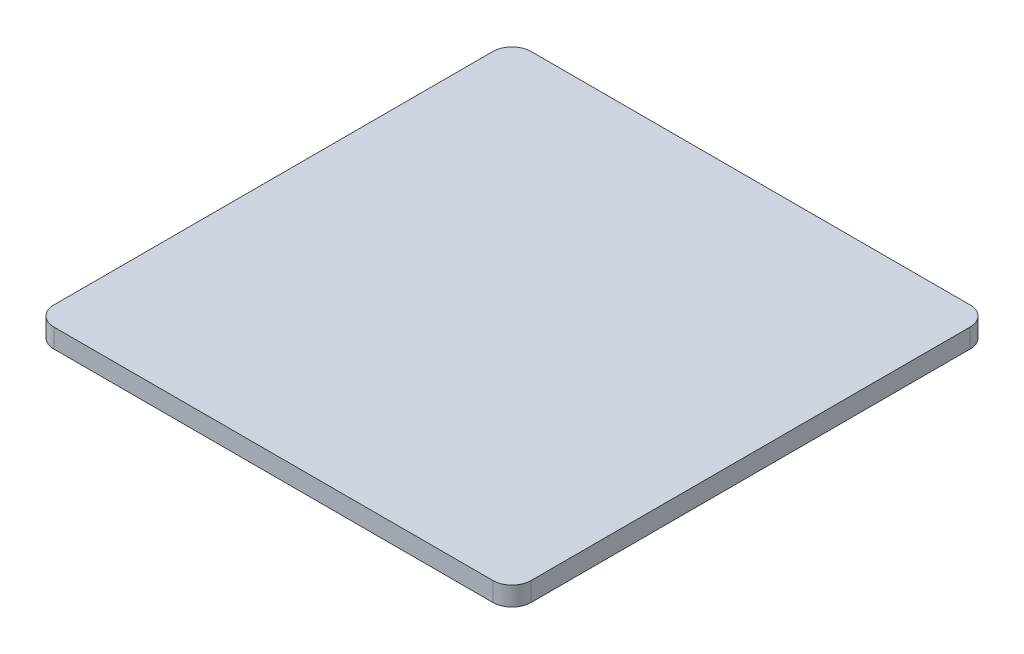
from build123d import *

# Parameters (mm, degrees)
SKETCH1_W           = 127
SKETCH1_H           = 127
BOSS_EXTRUDE1_DEPTH = 5.08
FILLET1_R           = 5.08


with BuildPart() as part:
    # Sketch1 → Boss-Extrude1 (new body)
    with BuildSketch(Plane(origin=(0, 0, 0), x_dir=(1, 0, 0), z_dir=(0, 1, 0))):
        Rectangle(SKETCH1_W, SKETCH1_H)
    extrude(amount=BOSS_EXTRUDE1_DEPTH)

    # Fillet1
    fillet1_edges = [part.edges().sort_by_distance(p)[0] for p in [
        (-63.5, 2.54, -63.5),
        (63.5, 2.54, -63.5),
        (63.5, 2.54, 63.5),
        (-63.5, 2.54, 63.5),
    ]]
    fillet(fillet1_edges, radius=FILLET1_R)


solid = part.part
